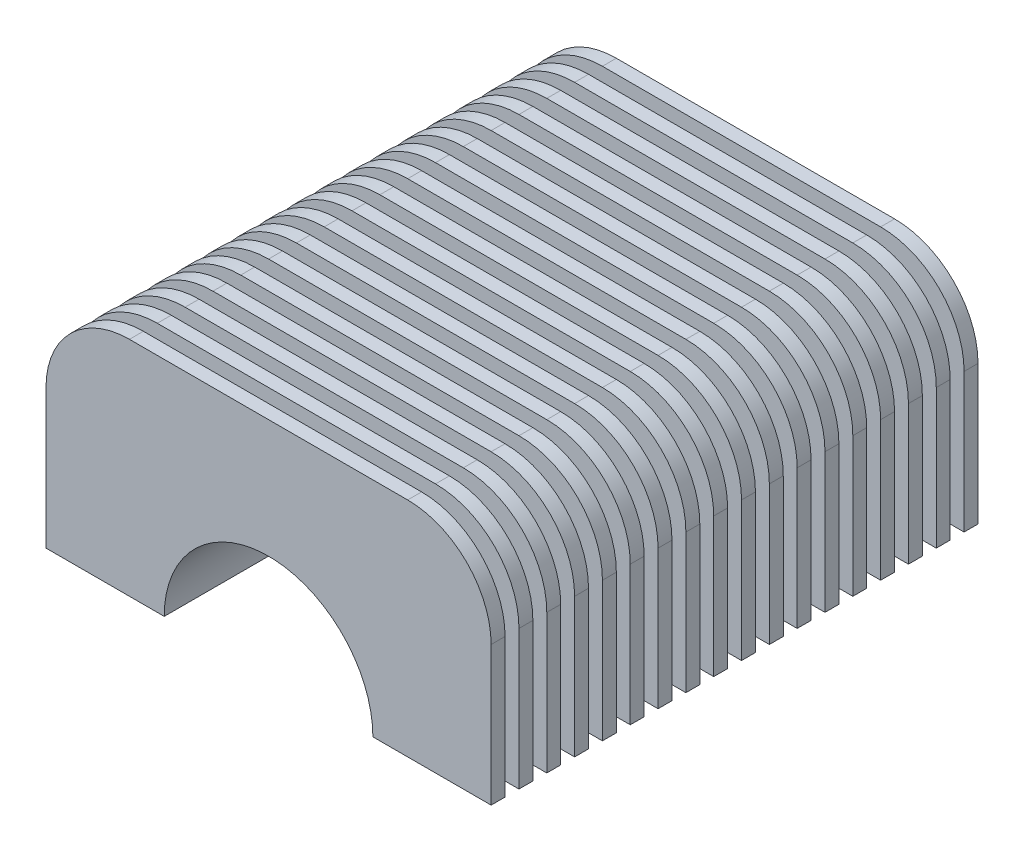
from build123d import *

# Parameters (mm, degrees)
DODANIE_WYCI_GNI_CIE1_DEPTH = 108
ZAOKR_GLENIE1_R             = 10
DODANIE_WYCI_GNI_CIE2_DEPTH = 3
SZYK_LINIOWY1_COUNT         = 18
SZYK_LINIOWY1_PITCH         = 6


with BuildPart() as part:
    # Szkic1 → Dodanie-wyciągnięcie1 (new body)
    with BuildSketch(Plane.XY):
        with BuildLine():
            Line((22.5, 0), (40, 0))
            Line((40, 0), (40, 40))
            Line((40, 40), (-40, 40))
            Line((-40, 40), (-40, 0))
            Line((-40, 0), (-22.5, 0))
            ThreePointArc((-22.5, 0), (0, 22.5), (22.5, 0))
        make_face()
    extrude(amount=-DODANIE_WYCI_GNI_CIE1_DEPTH)

    # Zaokrąglenie1
    zaokr_glenie1_edges = [part.edges().sort_by_distance(p)[0] for p in [
        (-40, 40, -54),
        (40, 40, -54),
    ]]
    fillet(zaokr_glenie1_edges, radius=ZAOKR_GLENIE1_R)

    # Szkic2 → Dodanie-wyciągnięcie2 (add)
    with BuildSketch(Plane.XY):
        with BuildLine():
            Line((40, 0), (40, 30))
            ThreePointArc((40, 30), (37.071067812, 37.071067812), (30, 40))
            Line((30, 40), (-30, 40))
            ThreePointArc((-30, 40), (-37.071067812, 37.071067812), (-40, 30))
            Line((-40, 30), (-40, 0))
            Line((-40, 0), (-48, 0))
            Line((-48, 0), (-48, 30))
            ThreePointArc((-48, 30), (-42.727922061, 42.727922061), (-30, 48))
            Line((-30, 48), (30, 48))
            ThreePointArc((30, 48), (42.727922061, 42.727922061), (48, 30))
            Line((48, 30), (48, 0))
            Line((48, 0), (40, 0))
        make_face()
    dodanie_wyci_gni_cie2 = extrude(amount=-DODANIE_WYCI_GNI_CIE2_DEPTH)

    # Szyk liniowy1: Dodanie-wyciągnięcie2 ×18
    with Locations(*[(0, 0, -i * SZYK_LINIOWY1_PITCH) for i in range(1, SZYK_LINIOWY1_COUNT)]):
        add(dodanie_wyci_gni_cie2)


solid = part.part
